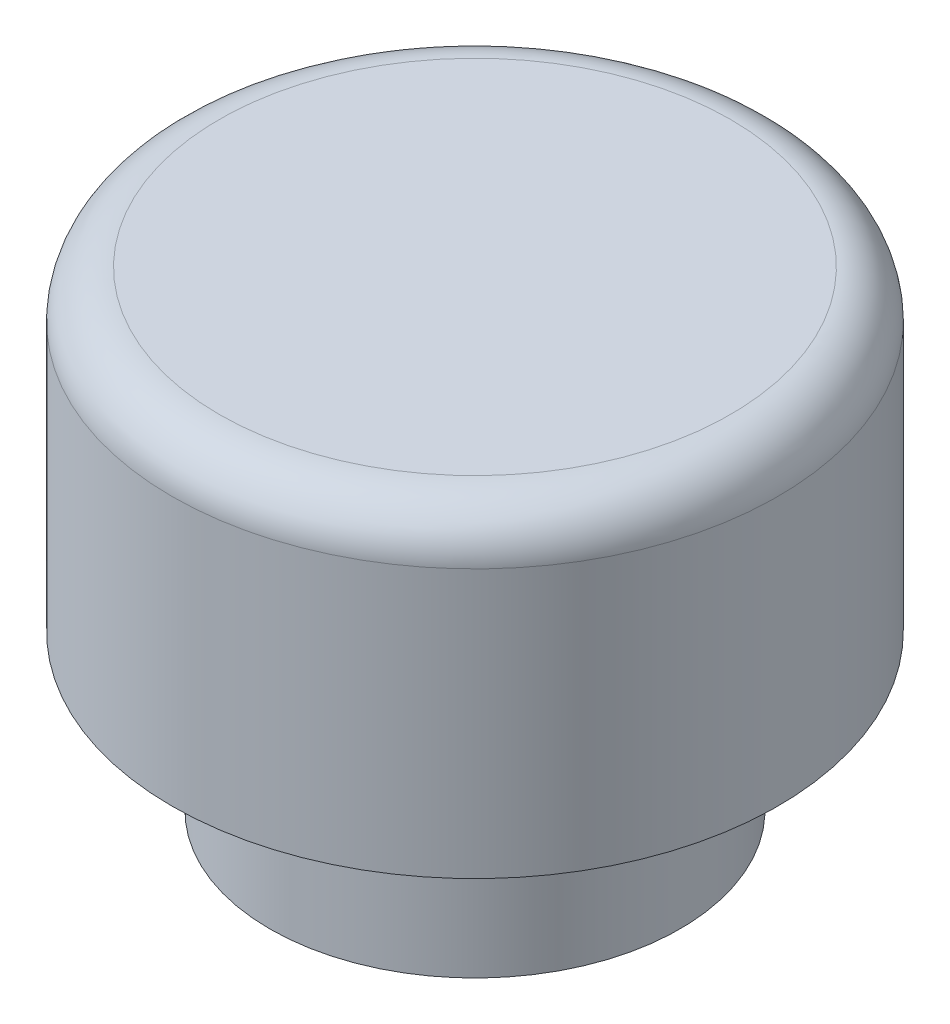
from build123d import *

# Parameters (mm, degrees)
SKETCH1_R           = 3.25
BOSS_EXTRUDE1_DEPTH = 2.46
SKETCH2_R           = 1.75
CUT_EXTRUDE1_DEPTH  = 3.35
SKETCH6_R           = 4.8
BOSS_EXTRUDE2_DEPTH = 5
FILLET1_R           = 0.75


with BuildPart() as part:
    # Sketch1 → Boss-Extrude1 (new body)
    with BuildSketch(Plane(origin=(0, 0, 0), x_dir=(1, 0, 0), z_dir=(0, 1, 0))):
        Circle(SKETCH1_R)
    extrude(amount=BOSS_EXTRUDE1_DEPTH)

    # Sketch2 → Cut-Extrude1 (cut)
    with BuildSketch(Plane.XZ):
        Circle(SKETCH2_R)
    extrude(amount=-CUT_EXTRUDE1_DEPTH, mode=Mode.SUBTRACT)

    # Sketch6 → Boss-Extrude2 (add)
    with BuildSketch(Plane(origin=(0, 2.46, 0), x_dir=(1, 0, 0), z_dir=(0, 1, 0))):
        Circle(SKETCH6_R)
    extrude(amount=BOSS_EXTRUDE2_DEPTH)

    # Fillet1
    fillet1_edges = [part.edges().sort_by_distance(p)[0] for p in [
        (-4.8, 7.46, 0),
    ]]
    fillet(fillet1_edges, radius=FILLET1_R)


solid = part.part
